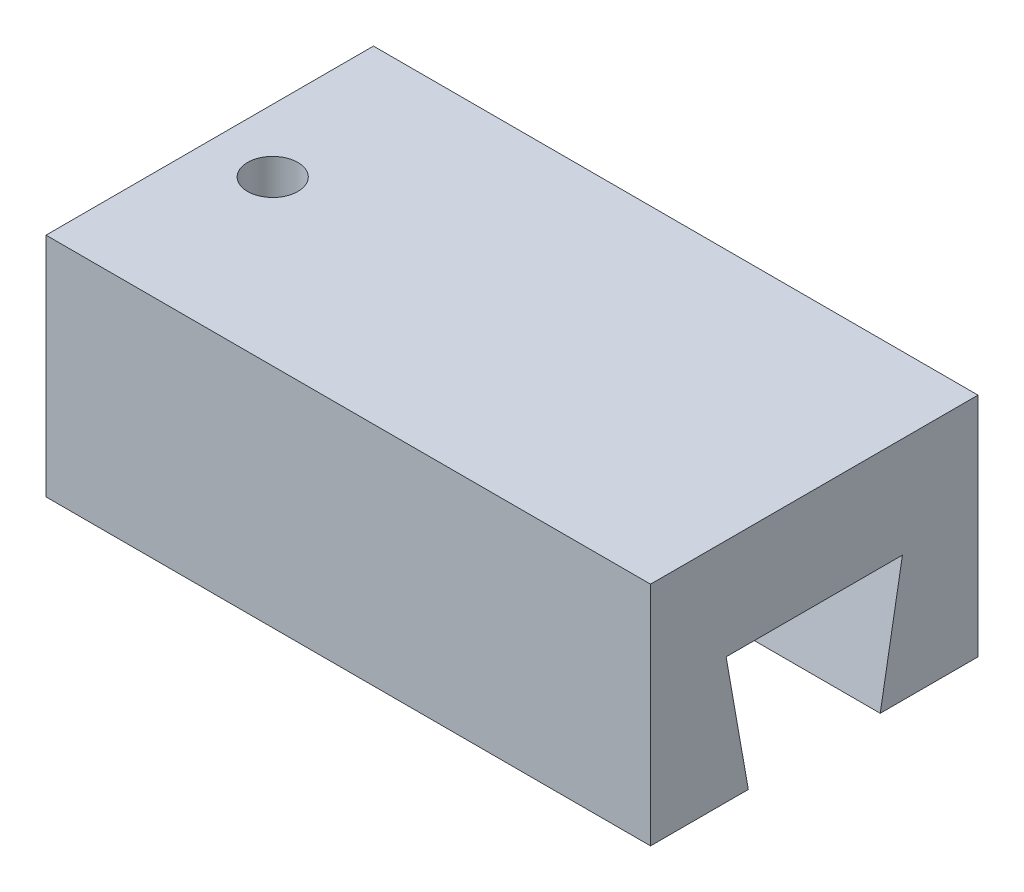
from build123d import *

# Parameters (mm, degrees)
SKETCH1_W               = 48
SKETCH1_H               = 26
BOSS_EXTRUDE1_DEPTH     = 18
CUT_EXTRUDE1_DEPTH      = 1
CUT_EXTRUDE1_DEPTH_BACK = 49
SKETCH3_R               = 2
CUT_EXTRUDE2_DEPTH      = 1
CUT_EXTRUDE2_DEPTH_BACK = 19


with BuildPart() as part:
    # Sketch1 → Boss-Extrude1 (new body)
    with BuildSketch(Plane(origin=(0, 0, 0), x_dir=(1, 0, 0), z_dir=(0, 1, 0))):
        with Locations((24, 13)):
            Rectangle(SKETCH1_W, SKETCH1_H)
    extrude(amount=BOSS_EXTRUDE1_DEPTH)

    # Sketch2 → Cut-Extrude1 (cut, two sides)
    with BuildSketch(Plane(origin=(48, 0, 0), x_dir=(0, 0, -1), z_dir=(1, 0, 0))) as cut_extrude1_sk:
        Polygon((6, 10), (20, 10), (18.236730193, 0), (7.763269807, 0), align=None)
    extrude(amount=CUT_EXTRUDE1_DEPTH, mode=Mode.SUBTRACT)
    extrude(cut_extrude1_sk.sketch, amount=-CUT_EXTRUDE1_DEPTH_BACK, mode=Mode.SUBTRACT)

    # Sketch3 → Cut-Extrude2 (cut, two sides)
    with BuildSketch(Plane(origin=(0, 18, 0), x_dir=(1, 0, 0), z_dir=(0, 1, 0))) as cut_extrude2_sk:
        with Locations((5, 13)):
            Circle(SKETCH3_R)
    extrude(amount=CUT_EXTRUDE2_DEPTH, mode=Mode.SUBTRACT)
    extrude(cut_extrude2_sk.sketch, amount=-CUT_EXTRUDE2_DEPTH_BACK, mode=Mode.SUBTRACT)


solid = part.part
